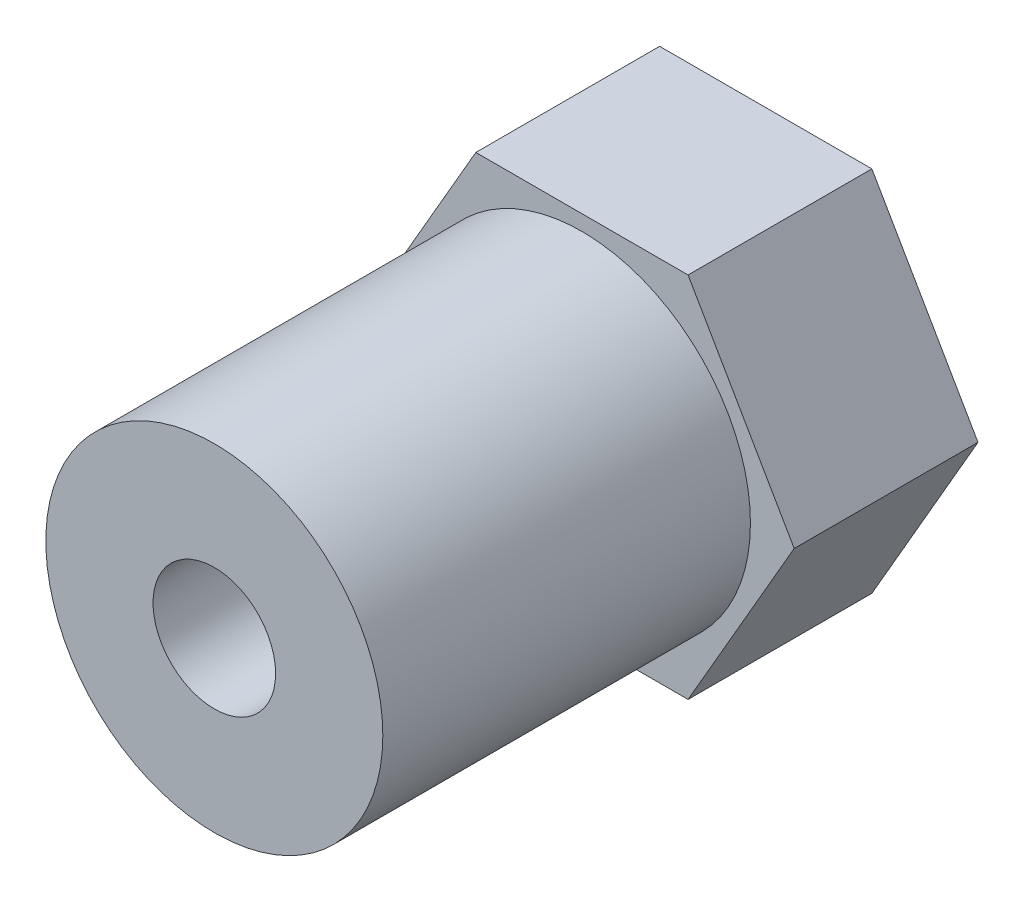
from build123d import *

# Parameters (mm, degrees)
SKETCH2_R           = 2
BOSS_EXTRUDE1_DEPTH = 6
SKETCH3_R           = 5.5
SKETCH3_R_2         = 2
BOSS_EXTRUDE2_DEPTH = 12


with BuildPart() as part:
    # Sketch2 → Boss-Extrude1 (new body)
    with BuildSketch(Plane.XY):
        Polygon((3.464101615, -6), (6.92820323, 0), (3.464101615, 6), (-3.464101615, 6), (-6.92820323, 0), (-3.464101615, -6), align=None)
        Circle(SKETCH2_R, mode=Mode.SUBTRACT)
    extrude(amount=BOSS_EXTRUDE1_DEPTH)

    # Sketch3 → Boss-Extrude2 (add)
    with BuildSketch(Plane.XY.offset(6)):
        Circle(SKETCH3_R)
        Circle(SKETCH3_R_2, mode=Mode.SUBTRACT)
    extrude(amount=BOSS_EXTRUDE2_DEPTH)


solid = part.part
